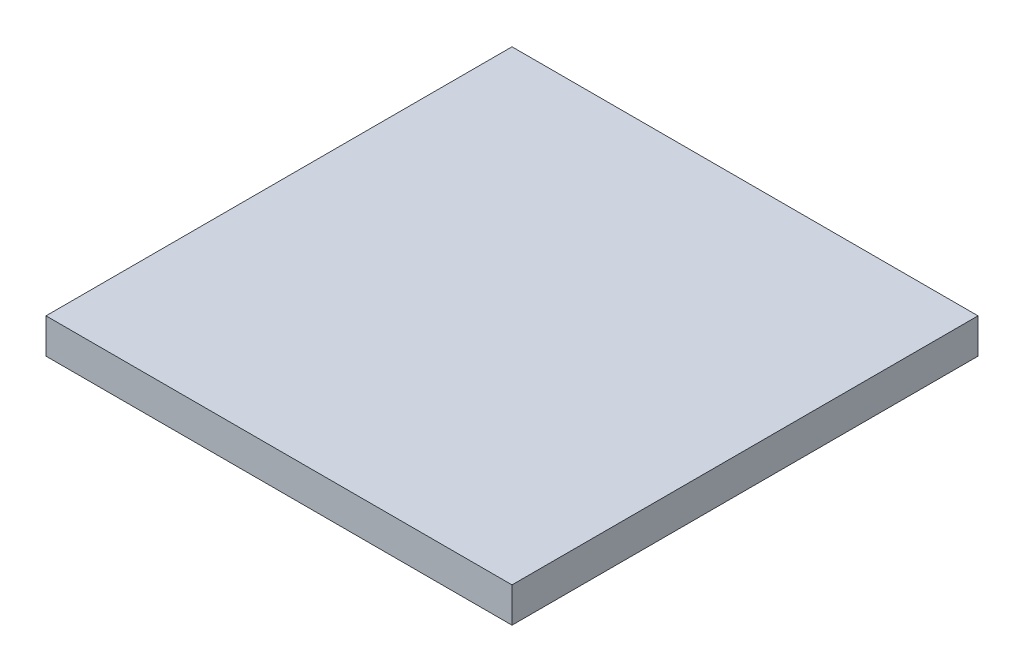
from build123d import *

# Parameters (mm, degrees)
CROQUIS1_W              = 508
CROQUIS1_H              = 38.1
SALIENTE_EXTRUIR1_DEPTH = 508


with BuildPart() as part:
    # Croquis1 → Saliente-Extruir1 (new body)
    with BuildSketch(Plane.XY):
        Rectangle(CROQUIS1_W, CROQUIS1_H)
    extrude(amount=-SALIENTE_EXTRUIR1_DEPTH)


solid = part.part
